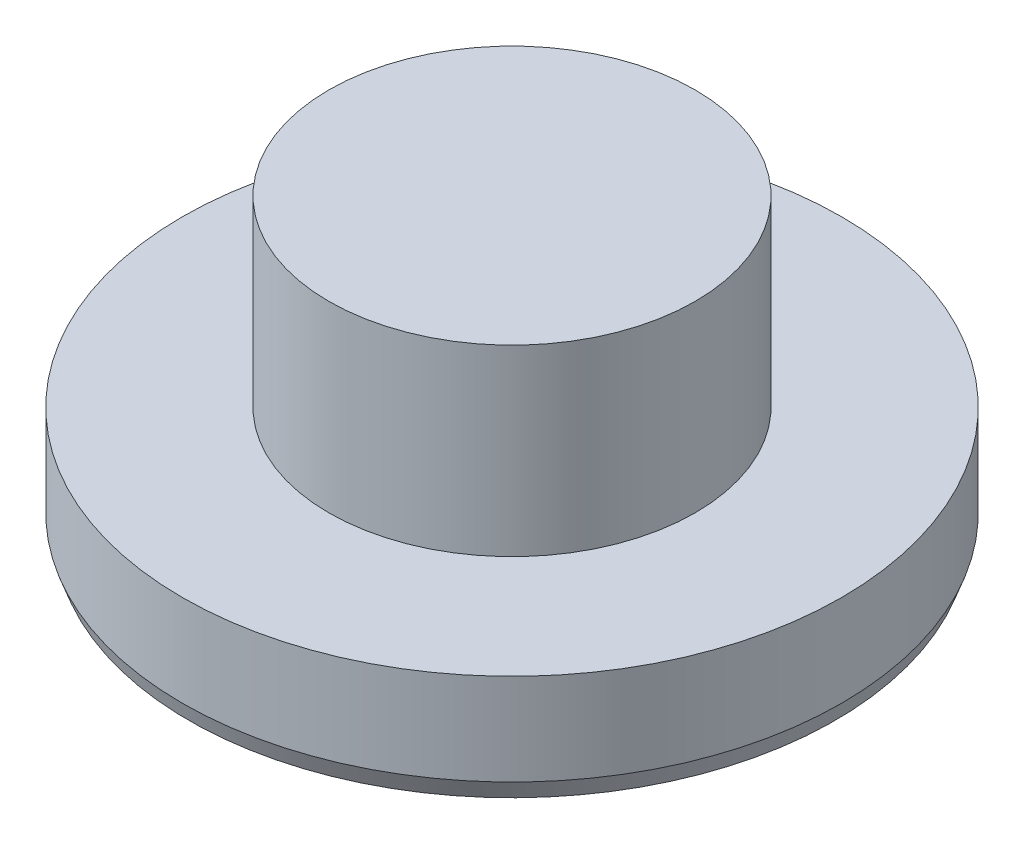
from build123d import *

# Parameters (mm, degrees)
SKETCH_3_R          = 6
CUT_EXTRUDE_1_DEPTH = 1
CHAMFER_1_SIZE      = 1
CHAMFER_1_SIZE2     = 0.363970234
CHAMFER_2_SIZE      = 0.5
CHAMFER_2_SIZE2     = 0.181985117


with BuildPart() as part:
    # Эскиз1 → Повернуть1 (revolve)
    with BuildSketch(Plane.XY):
        Polygon((0, 0), (0, 5), (5, 5), (5, 0), (9, 0), (9, -3), (0, -3), align=None)
    revolve(axis=Axis((0, 0, 0), (0, 1, 0)))

    # Эскиз3 → Вырез-Вытянуть1 (cut)
    with BuildSketch(Plane.XZ.offset(3)):
        Circle(SKETCH_3_R)
    extrude(amount=-CUT_EXTRUDE_1_DEPTH, mode=Mode.SUBTRACT)

    # Фаска1
    chamfer_1_edges = [part.edges().sort_by_distance(p)[0] for p in [
        (-6, -3, 0),
    ]]
    chamfer_1_side = [part.faces().sort_by_distance(p)[0] for p in [
        (-8.745441559, -3, 0),
    ]]
    chamfer(chamfer_1_edges, length=CHAMFER_1_SIZE, length2=CHAMFER_1_SIZE2, reference=chamfer_1_side[0])

    # Фаска2
    chamfer_2_edges = [part.edges().sort_by_distance(p)[0] for p in [
        (-9, -3, 0),
    ]]
    chamfer_2_side = [part.faces().sort_by_distance(p)[0] for p in [
        (-9, -1.5, 0),
    ]]
    chamfer(chamfer_2_edges, length=CHAMFER_2_SIZE, length2=CHAMFER_2_SIZE2, reference=chamfer_2_side[0])


solid = part.part
